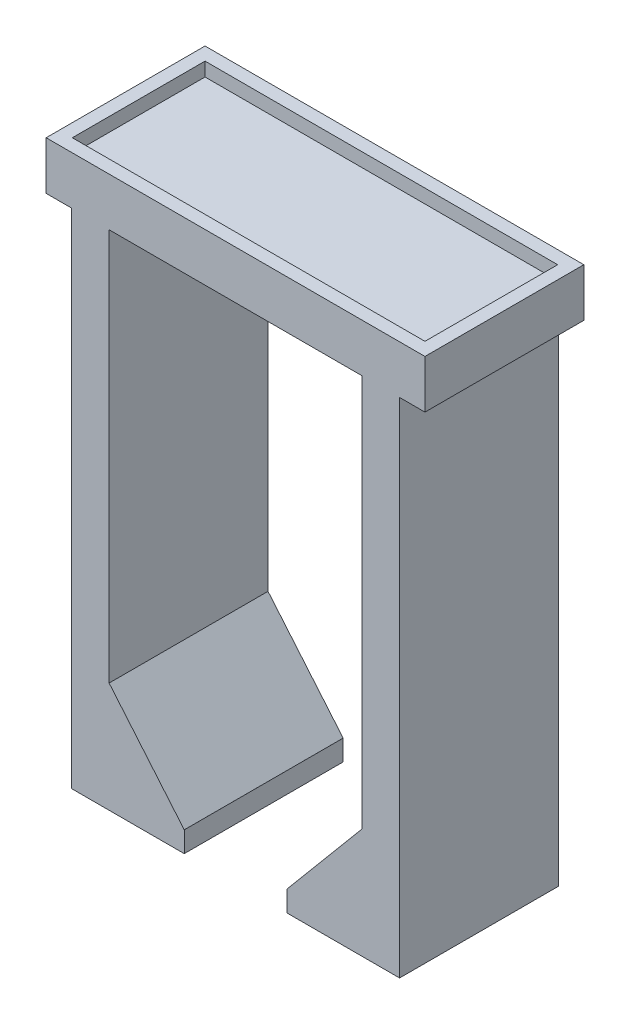
from build123d import *

# Parameters (mm, degrees)
SKETCH1_W                 = 7.82
SKETCH1_H                 = 51
BOSS_EXTRUDE1_DEPTH       = 25
SKETCH2_W                 = 55
SKETCH2_H                 = 23.07
BOSS_EXTRUDE2_DEPTH       = 5
SKETCH3_W                 = 55
SKETCH3_H                 = 23.07
SKETCH3_W_2               = 51.2
SKETCH3_H_2               = 19.27
BOSS_EXTRUDE3_DEPTH       = 2
FILLET1_R                 = 10
FILLET2_R                 = 3
SKETCH4_W                 = 3
SKETCH4_H                 = 10
BOSS_EXTRUDE4_DEPTH       = 2.5
CHAMFER1_SIZE             = 1
SKETCH5_W                 = 98.213610125
SKETCH5_H                 = 151.23254193
CUT_EXTRUDE1_DEPTH        = 30
SKETCH6_W                 = 5.457780719
SKETCH6_H                 = 23.07
BOSS_EXTRUDE5_DEPTH       = 70
SKETCH7_W                 = 16.36852431
SKETCH7_H                 = 23.07
BOSS_EXTRUDE6_DEPTH       = 3
CHAMFER2_SIZE             = 13
CHAMFER2_SIZE2            = 10.908295205
CHAMFER2_OF_MIRROR1_SIZE2 = 10.908295205
CHAMFER2_OF_MIRROR1_SIZE  = 13


with BuildPart() as part:
    # Sketch1 → Boss-Extrude1 (new body)
    with BuildSketch(Plane(origin=(0, 0, 0), x_dir=(1, 0, 0), z_dir=(0, 1, 0))):
        Rectangle(SKETCH1_W, SKETCH1_H)
    extrude(amount=BOSS_EXTRUDE1_DEPTH)

    # Sketch2 → Boss-Extrude2 (add)
    with BuildSketch(Plane(origin=(0, 25, 0), x_dir=(1, 0, 0), z_dir=(0, 1, 0))):
        Rectangle(SKETCH2_W, SKETCH2_H)
    extrude(amount=BOSS_EXTRUDE2_DEPTH)

    # Sketch3 → Boss-Extrude3 (add)
    with BuildSketch(Plane(origin=(0, 30, 0), x_dir=(1, 0, 0), z_dir=(0, 1, 0))):
        Rectangle(SKETCH3_W, SKETCH3_H)
        Rectangle(SKETCH3_W_2, SKETCH3_H_2, mode=Mode.SUBTRACT)
    extrude(amount=BOSS_EXTRUDE3_DEPTH)

    # Fillet1
    fillet1_edges = [part.edges().sort_by_distance(p)[0] for p in [
        (-3.91, 25, 0),
    ]]
    fillet(fillet1_edges, radius=FILLET1_R)

    # Fillet2
    fillet2_edges = [part.edges().sort_by_distance(p)[0] for p in [
        (3.91, 25, 0),
    ]]
    fillet(fillet2_edges, radius=FILLET2_R)

    # Sketch4 → Boss-Extrude4 (add)
    with BuildSketch(Plane.ZY.offset(3.91)):
        Rectangle(SKETCH4_W, SKETCH4_H)
    extrude(amount=BOSS_EXTRUDE4_DEPTH)

    # Chamfer1
    chamfer1_edges = [part.edges().sort_by_distance(p)[0] for p in [
        (-3.91, 2.5, 1.5),
        (-3.91, 5, 0),
        (-3.91, 2.5, -1.5),
    ]]
    chamfer(chamfer1_edges, length=CHAMFER1_SIZE)

    # Sketch5 → Cut-Extrude1 (cut)
    with BuildSketch(Plane(origin=(0, -5, 0), x_dir=(-1, 0, 0), z_dir=(0, -1, 0))):
        with Locations((5.202747623, 0)):
            Rectangle(SKETCH5_W, SKETCH5_H)
    extrude(amount=-CUT_EXTRUDE1_DEPTH, mode=Mode.SUBTRACT)

    # Sketch6 → Boss-Extrude5 (add)
    with BuildSketch(Plane(origin=(0, 25, 0), x_dir=(-1, 0, 0), z_dir=(0, -1, 0))):
        with Locations((-21.087107753, 0)):
            Rectangle(SKETCH6_W, SKETCH6_H)
    boss_extrude5 = extrude(amount=BOSS_EXTRUDE5_DEPTH)

    # Sketch7 → Boss-Extrude6 (add)
    with BuildSketch(Plane(origin=(0, -45, 0), x_dir=(-1, 0, 0), z_dir=(0, -1, 0))):
        with Locations((-15.631735957, 0)):
            Rectangle(SKETCH7_W, SKETCH7_H)
    boss_extrude6 = extrude(amount=BOSS_EXTRUDE6_DEPTH)

    # Chamfer2
    chamfer2_edges = [part.edges().sort_by_distance(p)[0] for p in [
        (18.358217393, -45, 0),
    ]]
    chamfer2_side = [part.faces().sort_by_distance(p)[0] for p in [
        (18.358217393, -10, 0),
    ]]
    chamfer(chamfer2_edges, length=CHAMFER2_SIZE, length2=CHAMFER2_SIZE2, reference=chamfer2_side[0])

    # Mirror1: Boss-Extrude5, Boss-Extrude6 across plane
    add(boss_extrude5.mirror(Plane(origin=(0, 0, 0), x_dir=(0, 0, 1), z_dir=(1, 0, 0))))
    add(boss_extrude6.mirror(Plane(origin=(0, 0, 0), x_dir=(0, 0, 1), z_dir=(1, 0, 0))))

    # Chamfer2 of Mirror1
    chamfer2_of_mirror1_edges = [part.edges().sort_by_distance(p)[0] for p in [
        (-18.358217393, -45, 0),
    ]]
    chamfer(chamfer2_of_mirror1_edges, length=CHAMFER2_OF_MIRROR1_SIZE, length2=CHAMFER2_OF_MIRROR1_SIZE2)


solid = part.part
